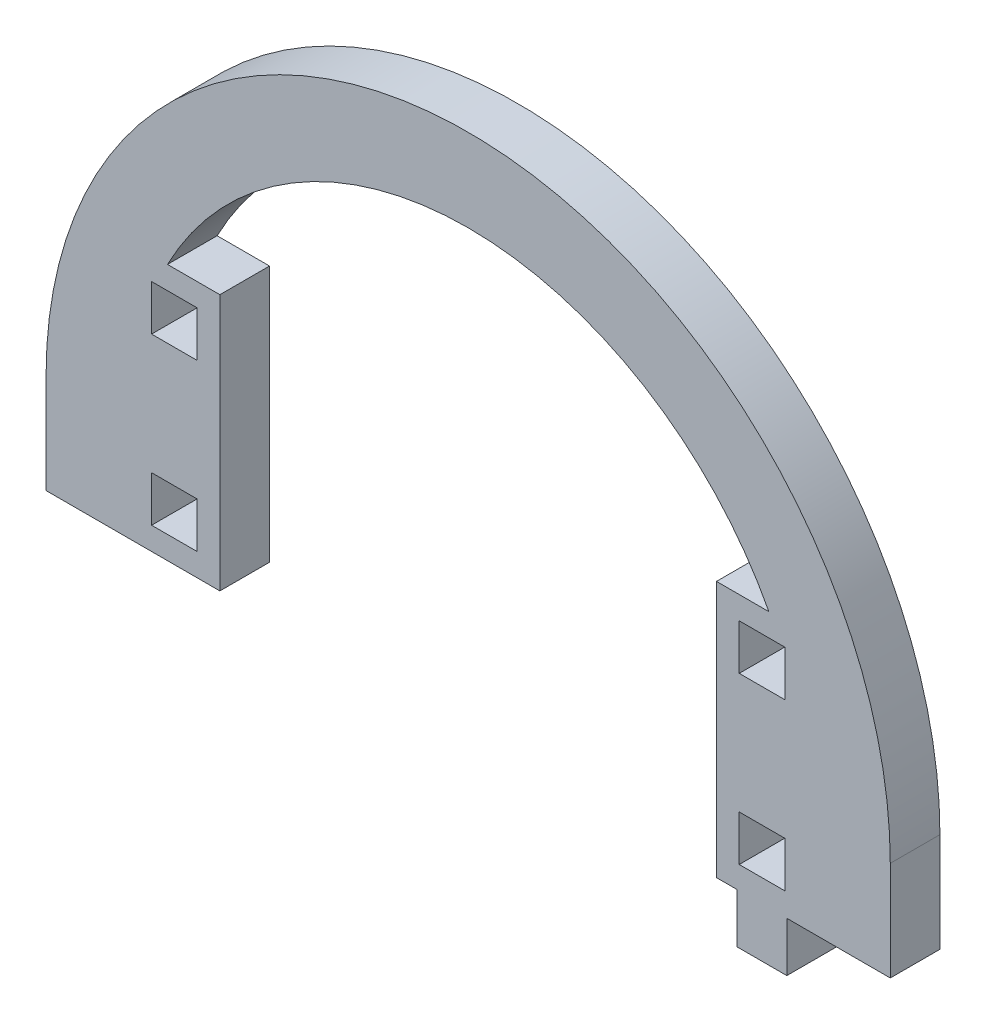
from build123d import *

# Parameters (mm, degrees)
MODEL_W             = 5.5
MODEL_H             = 5.5
BOSS_EXTRUDE1_DEPTH = 6


with BuildPart() as part:
    # Model → Boss-Extrude1 (new body)
    with BuildSketch(Plane.XY):
        with BuildLine():
            Line((3012.617094743, 1236.947244933), (3012.617094743, 1224.947244933))
            Line((3012.617094743, 1224.947244933), (3022.617094743, 1224.947244933))
            Line((3022.617094743, 1224.947244933), (3033.617094743, 1224.947244933))
            Line((3033.617094743, 1224.947244933), (3033.617094743, 1255.947244933))
            Line((3033.617094743, 1255.947244933), (3027.285290494, 1255.947244933))
            ThreePointArc((3027.285290494, 1255.947244933), (3063.617094743, 1277.947244933), (3099.948898993, 1255.947244933))
            Line((3099.948898993, 1255.947244933), (3093.617094743, 1255.947244933))
            Line((3093.617094743, 1255.947244933), (3093.617094743, 1224.947244933))
            Line((3093.617094743, 1224.947244933), (3096.117094743, 1224.947244933))
            Line((3096.117094743, 1224.947244933), (3096.117094743, 1218.947244933))
            Line((3096.117094743, 1218.947244933), (3102.117094743, 1218.947244933))
            Line((3102.117094743, 1218.947244933), (3102.117094743, 1224.947244933))
            Line((3102.117094743, 1224.947244933), (3114.617094743, 1224.947244933))
            Line((3114.617094743, 1224.947244933), (3114.617094743, 1236.947244933))
            ThreePointArc((3114.617094743, 1236.947244933), (3063.617094743, 1287.947244933), (3012.617094743, 1236.947244933))
        make_face()
        with Locations((3099.117094743, 1230.447244933)):
            Rectangle(MODEL_W, MODEL_H, mode=Mode.SUBTRACT)
        with Locations((3099.117094743, 1250.447244933)):
            Rectangle(MODEL_W, MODEL_H, mode=Mode.SUBTRACT)
        with Locations((3028.117094743, 1230.447244933)):
            Rectangle(MODEL_W, MODEL_H, mode=Mode.SUBTRACT)
        with Locations((3028.117094743, 1250.447244933)):
            Rectangle(MODEL_W, MODEL_H, mode=Mode.SUBTRACT)
    extrude(amount=BOSS_EXTRUDE1_DEPTH)


solid = part.part
